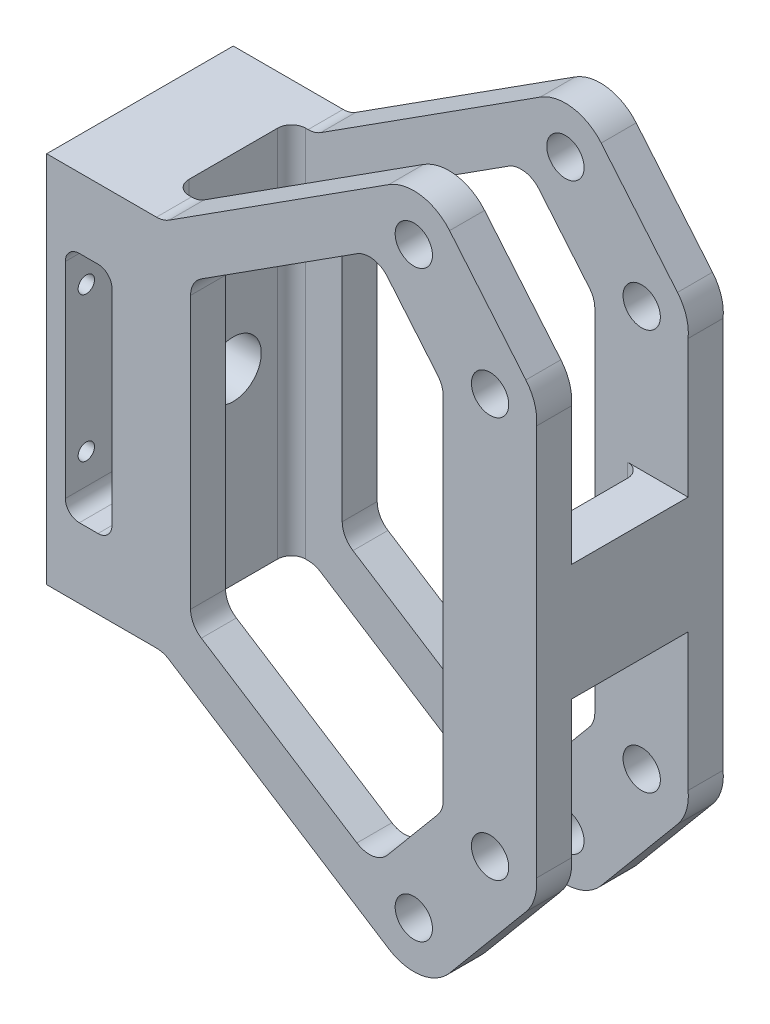
from build123d import *

# Parameters (mm, degrees)
SKETCH1_R               = 4
BOSS_EXTRUDE1_DEPTH     = 40
SKETCH2_W               = 100
SKETCH2_H               = 25
CUT_EXTRUDE1_DEPTH      = 113.5
CUT_EXTRUDE1_DEPTH_BACK = 33.5
SKETCH3_W               = 25
SKETCH3_H               = 25
BOSS_EXTRUDE2_DEPTH     = 10
SKETCH4_R               = 6
CUT_EXTRUDE2_DEPTH      = 100
FILLET1_R               = 5
FILLET2_R               = 3
SKETCH5_R               = 1.75
CUT_EXTRUDE3_DEPTH      = 10
SKETCH7_W               = 10
SKETCH7_H               = 50
CUT_EXTRUDE4_DEPTH      = 10
FILLET3_R               = 3
FILLET3_OF_MIRROR1_R    = 3
SKETCH8_R               = 12.5
CUT_EXTRUDE5_DEPTH      = 3


with BuildPart() as part:
    # Sketch1 → Boss-Extrude1 (new body)
    with BuildSketch(Plane.XY):
        with BuildLine():
            Line((25, 0), (73.308886978, -30.922345302))
            ThreePointArc((73.308886978, -30.922345302), (80.218691228, -32.384006119), (86.370944241, -28.915342115))
            Line((86.370944241, -28.915342115), (102.720944241, -9.365342115))
            ThreePointArc((102.720944241, -9.365342115), (104.608588105, -5.888263678), (105, -1.951250782))
            Line((105, -1.951250782), (105, 0))
            Line((105, 0), (105, 80))
            Line((105, 80), (105, 81.951250782))
            ThreePointArc((105, 81.951250782), (104.608588105, 85.888263678), (102.720944241, 89.365342115))
            Line((102.720944241, 89.365342115), (86.370944241, 108.915342115))
            ThreePointArc((86.370944241, 108.915342115), (80.218691228, 112.384006119), (73.308886978, 110.922345302))
            Line((73.308886978, 110.922345302), (25, 80))
            Line((25, 80), (0, 80))
            Line((0, 80), (0, 0))
            Line((0, 0), (25, 0))
        make_face()
        with Locations((78.7, -22.5)):
            Circle(SKETCH1_R, mode=Mode.SUBTRACT)
        with Locations((95.05, -2.95)):
            Circle(SKETCH1_R, mode=Mode.SUBTRACT)
        with Locations((78.7, 102.5)):
            Circle(SKETCH1_R, mode=Mode.SUBTRACT)
        with Locations((95.05, 82.95)):
            Circle(SKETCH1_R, mode=Mode.SUBTRACT)
        Polygon((30.852797713, 71.873177413), (30.852797713, 8.126822587), (70.209148437, -17.065036365), (85, 0.620660764), (85, 79.379339236), (70.209148437, 97.065036365), align=None, mode=Mode.SUBTRACT)
    extrude(amount=-BOSS_EXTRUDE1_DEPTH)

    # Sketch2 → Cut-Extrude1 (cut, two sides)
    with BuildSketch(Plane(origin=(0, 0, 0), x_dir=(1, 0, 0), z_dir=(0, 1, 0))) as cut_extrude1_sk:
        with Locations((70, 20)):
            Rectangle(SKETCH2_W, SKETCH2_H)
    extrude(amount=CUT_EXTRUDE1_DEPTH, mode=Mode.SUBTRACT)
    extrude(cut_extrude1_sk.sketch, amount=-CUT_EXTRUDE1_DEPTH_BACK, mode=Mode.SUBTRACT)

    # Sketch3 → Boss-Extrude2 (add)
    with BuildSketch(Plane(origin=(105, 0, 0), x_dir=(0, 0, -1), z_dir=(1, 0, 0))):
        with Locations((20, 40)):
            Rectangle(SKETCH3_W, SKETCH3_H)
    extrude(amount=-BOSS_EXTRUDE2_DEPTH)

    # Sketch4 → Cut-Extrude2 (cut)
    with BuildSketch(Plane.ZY):
        with Locations((-20, 40)):
            Circle(SKETCH4_R)
    extrude(amount=-CUT_EXTRUDE2_DEPTH, mode=Mode.SUBTRACT)

    # Fillet1
    fillet1_edges = [part.edges().sort_by_distance(p)[0] for p in [
        (25, 80, -3.75),
        (25, 80, -36.25),
        (25, 0, -36.25),
        (85, 79.379339236, -36.25),
        (85, 0.620660764, -36.25),
        (70.209148437, -17.065036365, -36.25),
        (30.852797713, 8.126822587, -36.25),
        (30.852797713, 71.873177413, -36.25),
        (70.209148437, 97.065036365, -36.25),
        (70.209148437, 97.065036365, -3.75),
        (85, 79.379339236, -3.75),
        (30.852797713, 71.873177413, -3.75),
        (30.852797713, 8.126822587, -3.75),
        (70.209148437, -17.065036365, -3.75),
        (85, 0.620660764, -3.75),
        (25, 0, -3.75),
    ]]
    fillet(fillet1_edges, radius=FILLET1_R)

    # Fillet2
    fillet2_edges = [part.edges().sort_by_distance(p)[0] for p in [
        (20, 40, -32.5),
        (20, 40, -7.5),
        (95, 40, -32.5),
        (95, 40, -7.5),
    ]]
    fillet(fillet2_edges, radius=FILLET2_R)

    # Sketch5 → Cut-Extrude3 (cut)
    with BuildSketch(Plane.ZY):
        with Locations((-35.5, 55.5)):
            Circle(SKETCH5_R)
        with Locations((-4.5, 55.5)):
            Circle(SKETCH5_R)
        with Locations((-35.5, 24.5)):
            Circle(SKETCH5_R)
        with Locations((-4.5, 24.5)):
            Circle(SKETCH5_R)
    extrude(amount=-CUT_EXTRUDE3_DEPTH, mode=Mode.SUBTRACT)

    # Sketch7 → Cut-Extrude4 (cut)
    with BuildSketch(Plane.XY):
        with Locations((9, 40)):
            Rectangle(SKETCH7_W, SKETCH7_H)
    cut_extrude4 = extrude(amount=-CUT_EXTRUDE4_DEPTH, mode=Mode.SUBTRACT)

    # Fillet3
    fillet3_edges = [part.edges().sort_by_distance(p)[0] for p in [
        (4, 15, -5),
        (4, 65, -5),
        (14, 65, -5),
        (14, 15, -5),
    ]]
    fillet(fillet3_edges, radius=FILLET3_R)

    # Mirror1: Cut-Extrude4 across plane
    add(cut_extrude4.mirror(Plane.XY.offset(-20)), mode=Mode.SUBTRACT)

    # Fillet3 of Mirror1
    fillet3_of_mirror1_edges = [part.edges().sort_by_distance(p)[0] for p in [
        (4, 15, -35),
        (4, 65, -35),
        (14, 65, -35),
        (14, 15, -35),
    ]]
    fillet(fillet3_of_mirror1_edges, radius=FILLET3_OF_MIRROR1_R)

    # Sketch8 → Cut-Extrude5 (cut)
    with BuildSketch(Plane.ZY):
        with Locations((-20, 40)):
            Circle(SKETCH8_R)
    extrude(amount=-CUT_EXTRUDE5_DEPTH, mode=Mode.SUBTRACT)


solid = part.part
